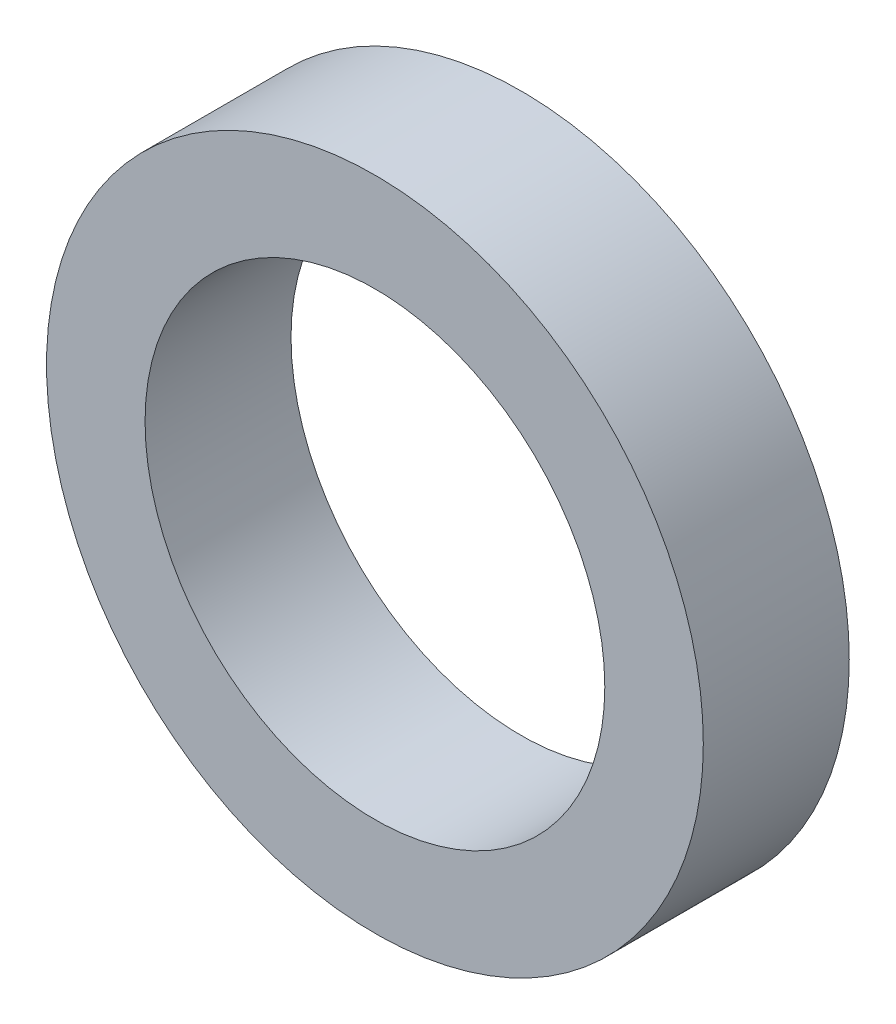
from build123d import *

# Parameters (mm, degrees)
SKETCH_1_R      = 22.5
SKETCH_1_R_2    = 15.75
EXTRUDE_1_DEPTH = 10


with BuildPart() as part:
    # Эскиз1 → Вытянуть1 (new body)
    with BuildSketch(Plane.XY):
        Circle(SKETCH_1_R)
        Circle(SKETCH_1_R_2, mode=Mode.SUBTRACT)
    extrude(amount=EXTRUDE_1_DEPTH)


solid = part.part
